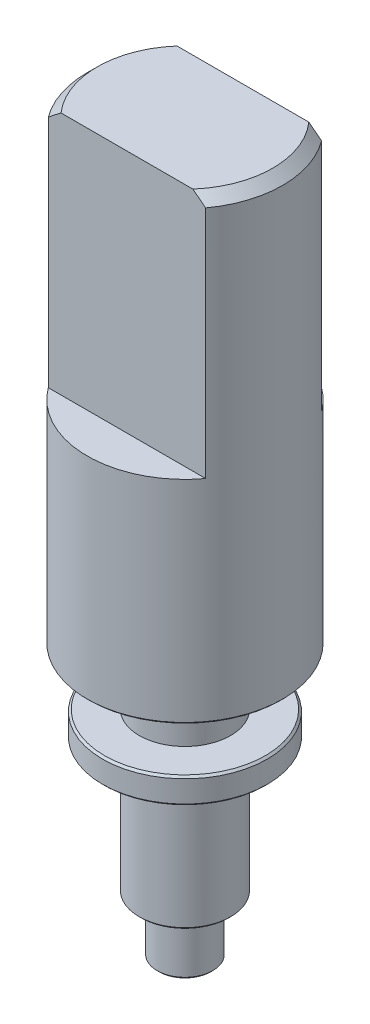
from build123d import *

# Parameters (mm, degrees)
CUT_EXTRUDE_1_DEPTH = 6.15
CHAMFER_1_SIZE      = 0.25
CHAMFER_2_SIZE      = 0.05


with BuildPart() as part:
    # Эскиз1 → Повернуть1 (revolve)
    with BuildSketch(Plane.XY):
        Polygon((0, 18.3), (0, 0), (-0.7, 0), (-0.7, 1.4), (-1.15, 1.4), (-1.15, 4.75), (-2.075, 4.75), (-2.075, 5.4), (-1.15, 5.4), (-1.15, 6.8), (-2.46, 6.8), (-2.46, 18.3), align=None)
    revolve(axis=Axis((0, 18.3, 0), (0, -1, 0)))

    # Эскиз2 → Вырез-Вытянуть1 (cut)
    with BuildSketch(Plane(origin=(0, 18.3, 0), x_dir=(1, 0, 0), z_dir=(0, 1, 0))):
        with BuildLine():
            Line((-1.979898987, 1.46), (1.979898987, 1.46))
            ThreePointArc((1.979898987, 1.46), (0, 2.46), (-1.979898987, 1.46))
        make_face()
        with BuildLine():
            Line((-1.979898987, -1.46), (1.979898987, -1.46))
            ThreePointArc((1.979898987, -1.46), (0, -2.46), (-1.979898987, -1.46))
        make_face()
    extrude(amount=-CUT_EXTRUDE_1_DEPTH, mode=Mode.SUBTRACT)

    # Фаска1
    chamfer_1_edges = [part.edges().sort_by_distance(p)[0] for p in [
        (-2.336894468, 18.3, -0.768455754),
        (2.46, 18.3, 0),
    ]]
    chamfer(chamfer_1_edges, length=CHAMFER_1_SIZE)

    # Фаска2
    chamfer_2_edges = [part.edges().sort_by_distance(p)[0] for p in [
        (2.075, 5.4, 0),
        (2.075, 4.75, 0),
        (1.15, 1.4, 0),
        (0.7, 0, 0),
        (2.46, 6.8, 0),
    ]]
    chamfer(chamfer_2_edges, length=CHAMFER_2_SIZE)


solid = part.part
